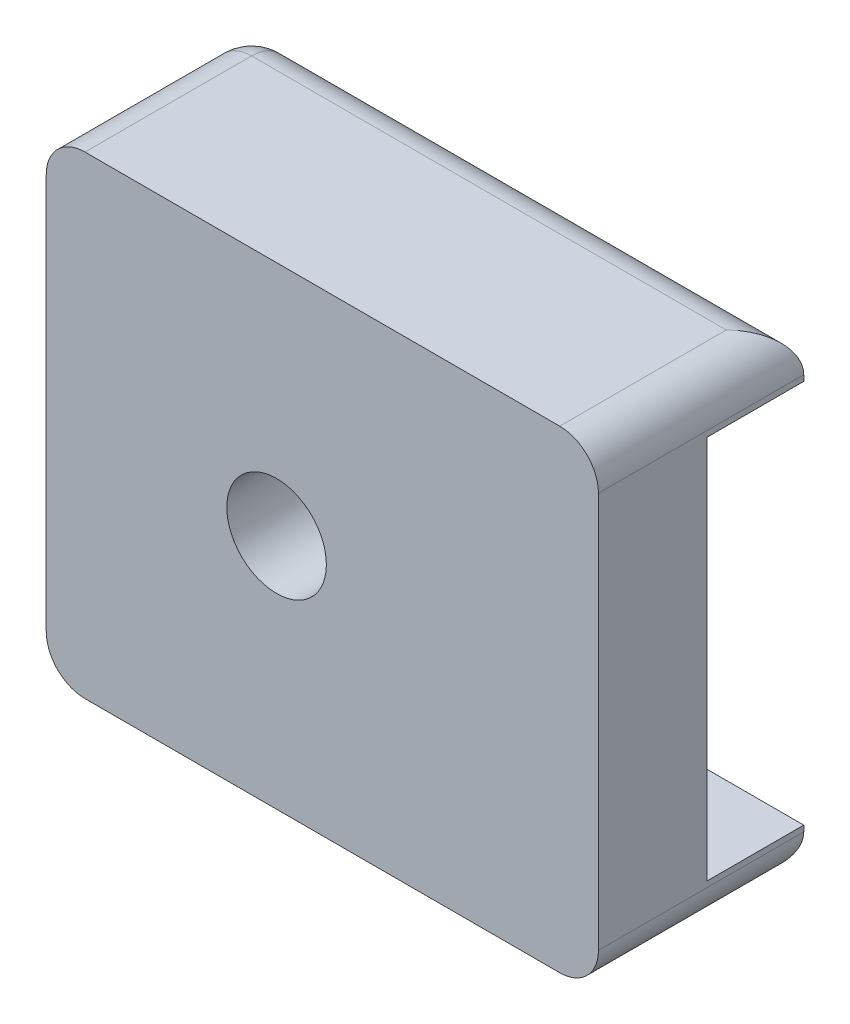
from build123d import *

# Parameters (mm, degrees)
SKETCH1_W           = 36.195
SKETCH1_H           = 31.027347648
SKETCH1_R           = 3.2639
BOSS_EXTRUDE1_DEPTH = 7.10692
BOSS_EXTRUDE3_DEPTH = 6.35
FILLET1_R           = 2.54


with BuildPart() as part:
    # Sketch1 → Boss-Extrude1 (new body)
    with BuildSketch(Plane.XY):
        with Locations((-48.5775, -7.089116399)):
            Rectangle(SKETCH1_W, SKETCH1_H)
        with Locations((-51.577868645, -7.089116399)):
            Circle(SKETCH1_R, mode=Mode.SUBTRACT)
    extrude(amount=BOSS_EXTRUDE1_DEPTH)

    # Sketch2 → Boss-Extrude3 (add)
    with BuildSketch(Plane(origin=(0, 0, 0), x_dir=(-1, 0, 0), z_dir=(0, 0, -1))):
        Polygon((30.48, -19.681790223), (30.48, -22.602790223), (66.675, -22.602790223), (66.675, 8.424557425), (30.48, 8.424557425), (30.48, 5.503557425), (63.754, 5.503557425), (63.754, -19.681790223), align=None)
    extrude(amount=BOSS_EXTRUDE3_DEPTH)

    # Fillet1
    fillet1_edges = [part.edges().sort_by_distance(p)[0] for p in [
        (-48.5775, 8.424557425, -6.35),
        (-66.675, -7.089116399, -6.35),
        (-48.5775, -22.602790223, -6.35),
        (-66.675, 8.424557425, 0.37846),
        (-30.48, 8.424557425, 0.37846),
        (-30.48, -22.602790223, 0.37846),
        (-66.675, -22.602790223, 0.37846),
    ]]
    fillet(fillet1_edges, radius=FILLET1_R)


solid = part.part
